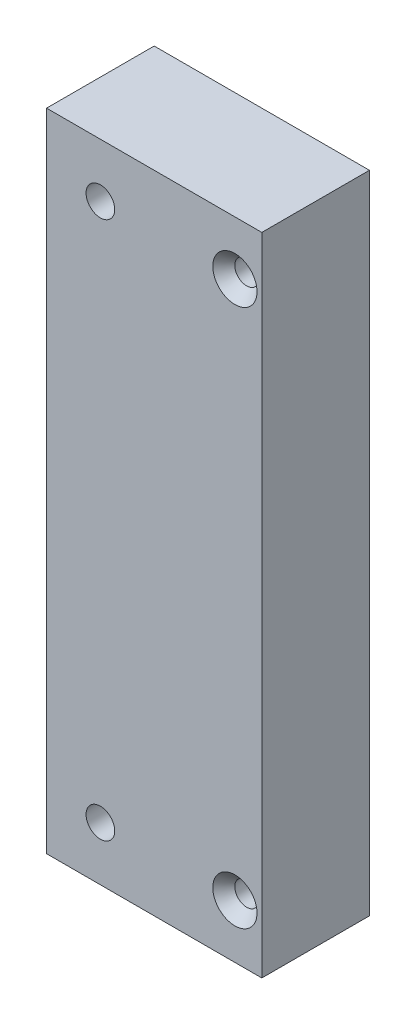
from build123d import *

# Parameters (mm, degrees)
SKETCH1_W                                          = 50.8
SKETCH1_H                                          = 152.4
SKETCH1_R                                          = 3.3782
BOSS_EXTRUDE1_DEPTH                                = 25.4
CSK_FOR_10_FLAT_HEAD_SOCKET_CAP_SCREW1_D           = 5.6134
CSK_FOR_10_FLAT_HEAD_SOCKET_CAP_SCREW1_CSINK_D     = 10.4394
CSK_FOR_10_FLAT_HEAD_SOCKET_CAP_SCREW1_CSINK_ANGLE = 82


with BuildPart() as part:
    # Sketch1 → Boss-Extrude1 (new body)
    with BuildSketch(Plane.XY):
        with Locations((330.2, 241.3)):
            Rectangle(SKETCH1_W, SKETCH1_H)
        with Locations((317.5, 304.8)):
            Circle(SKETCH1_R, mode=Mode.SUBTRACT)
        with Locations((317.5, 177.8)):
            Circle(SKETCH1_R, mode=Mode.SUBTRACT)
    extrude(amount=BOSS_EXTRUDE1_DEPTH)

    # CSK for #10 Flat Head Socket Cap Screw1 (through all)
    with Locations(Plane.XY.offset(25.4)):
        with Locations((349.25, 304.8), (349.25, 177.8)):
            CounterSinkHole(CSK_FOR_10_FLAT_HEAD_SOCKET_CAP_SCREW1_D / 2, CSK_FOR_10_FLAT_HEAD_SOCKET_CAP_SCREW1_CSINK_D / 2, counter_sink_angle=CSK_FOR_10_FLAT_HEAD_SOCKET_CAP_SCREW1_CSINK_ANGLE)


solid = part.part
